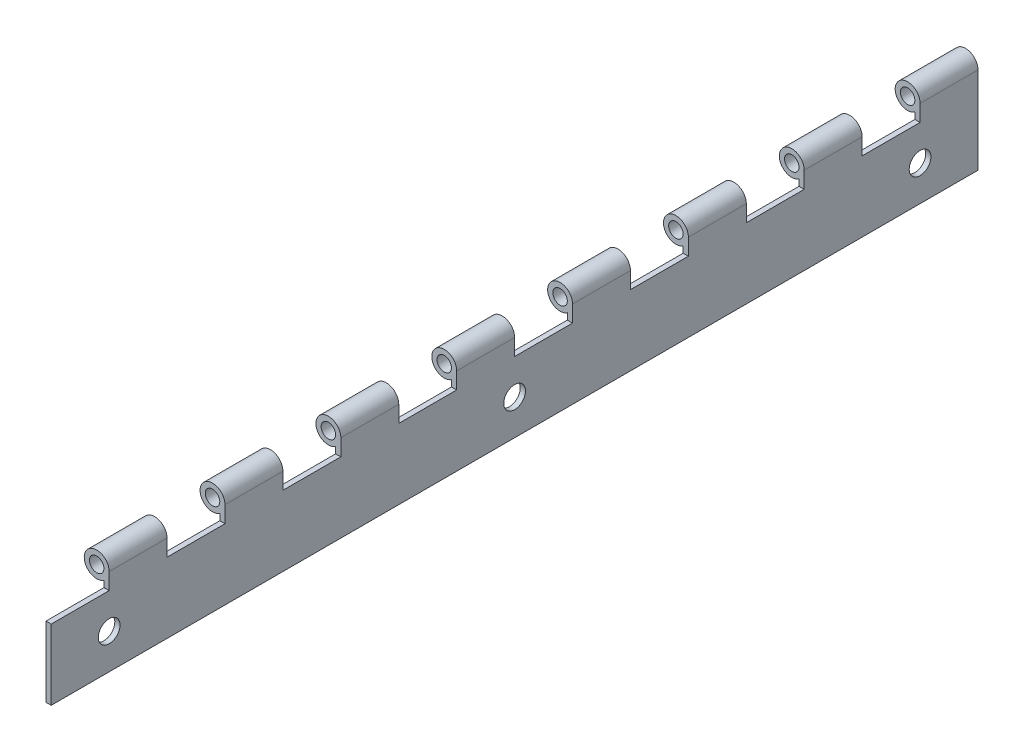
from build123d import *

# Parameters (mm, degrees)
SKETCH1_R           = 3.175
BOSS_EXTRUDE1_DEPTH = 406.4
SKETCH2_W           = 25.4
SKETCH2_H           = 12.7
CUT_EXTRUDE1_DEPTH  = 11.922
LPATTERN1_COUNT     = 8
LPATTERN1_PITCH     = 50.8
SKETCH3_R           = 4.7625
CUT_EXTRUDE2_DEPTH  = 3.286


with BuildPart() as part:
    # Sketch1 → Boss-Extrude1 (new body)
    with BuildSketch(Plane.XY):
        with BuildLine():
            Line((5.461, 0), (5.461, -38.1))
            Line((5.461, -38.1), (3.175, -38.1))
            Line((3.175, -38.1), (3.175, -4.443185344))
            ThreePointArc((3.175, -4.443185344), (-4.855985791, 2.498384078), (5.461, 0))
        make_face()
        Circle(SKETCH1_R, mode=Mode.SUBTRACT)
    extrude(amount=BOSS_EXTRUDE1_DEPTH)

    # Sketch2 → Cut-Extrude1 (cut, through all)
    with BuildSketch(Plane(origin=(5.461, 0, 0), x_dir=(0, 0, -1), z_dir=(1, 0, 0))):
        with Locations((-393.7, -0.889)):
            Rectangle(SKETCH2_W, SKETCH2_H)
    cut_extrude1 = extrude(amount=-CUT_EXTRUDE1_DEPTH, mode=Mode.SUBTRACT)

    # LPattern1: Cut-Extrude1 ×8
    with Locations(*[(0, 0, -i * LPATTERN1_PITCH) for i in range(1, LPATTERN1_COUNT)]):
        add(cut_extrude1, mode=Mode.SUBTRACT)

    # Sketch3 → Cut-Extrude2 (cut, through all)
    with BuildSketch(Plane.ZY.offset(-3.175)):
        with Locations((25.4, -22.6695)):
            Circle(SKETCH3_R)
        with Locations((203.2, -22.6695)):
            Circle(SKETCH3_R)
        with Locations((381, -22.6695)):
            Circle(SKETCH3_R)
    extrude(amount=-CUT_EXTRUDE2_DEPTH, mode=Mode.SUBTRACT)


solid = part.part
